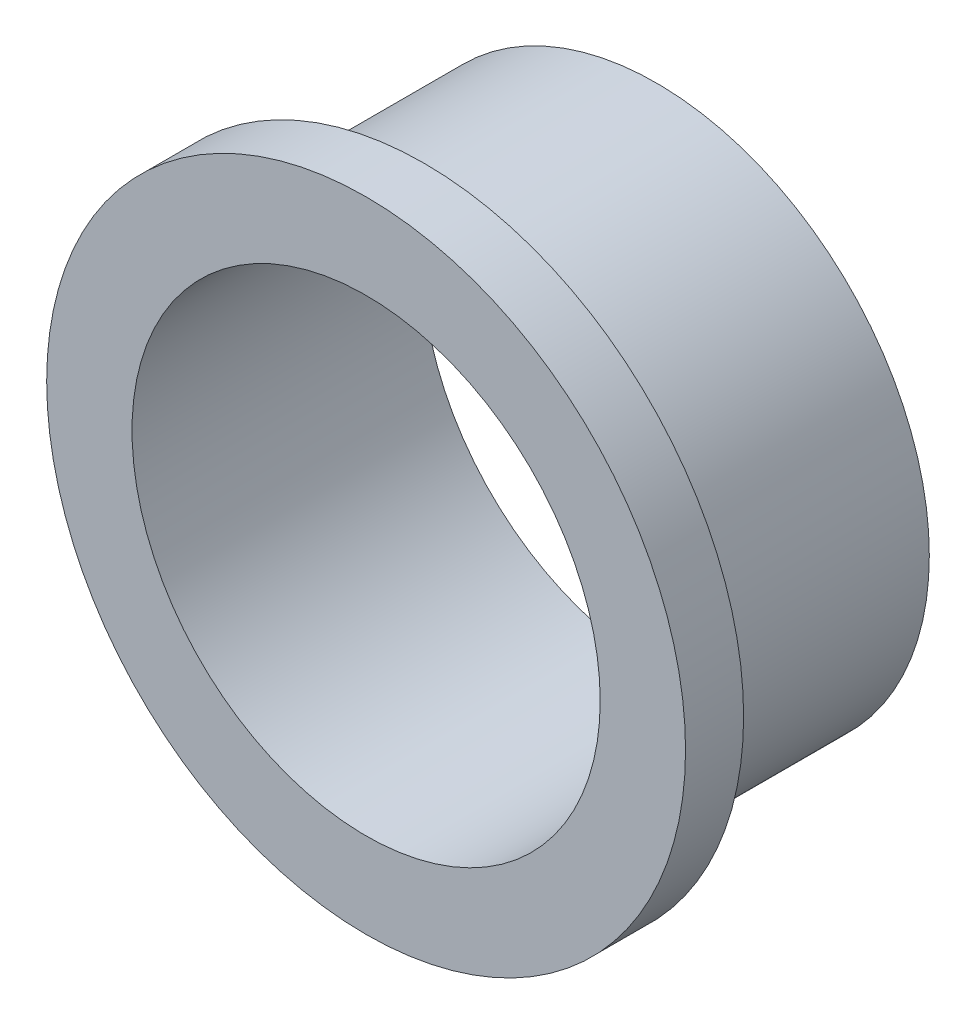
from build123d import *


with BuildPart() as part:
    # Sketch5 → Base-Revolve (revolve)
    with BuildSketch(Plane(origin=(0, 0, 0), x_dir=(-1, 0, 0), z_dir=(0, 1, 0))):
        Polygon((-7.158618567, -6.096), (-6.142618567, -6.096), (-6.142618567, 1.524), (-8.382, 1.524), (-8.382, 0), (-7.158618567, 0), align=None)
    revolve(axis=Axis((0, 0, 0), (0, 0, -1)))


solid = part.part
